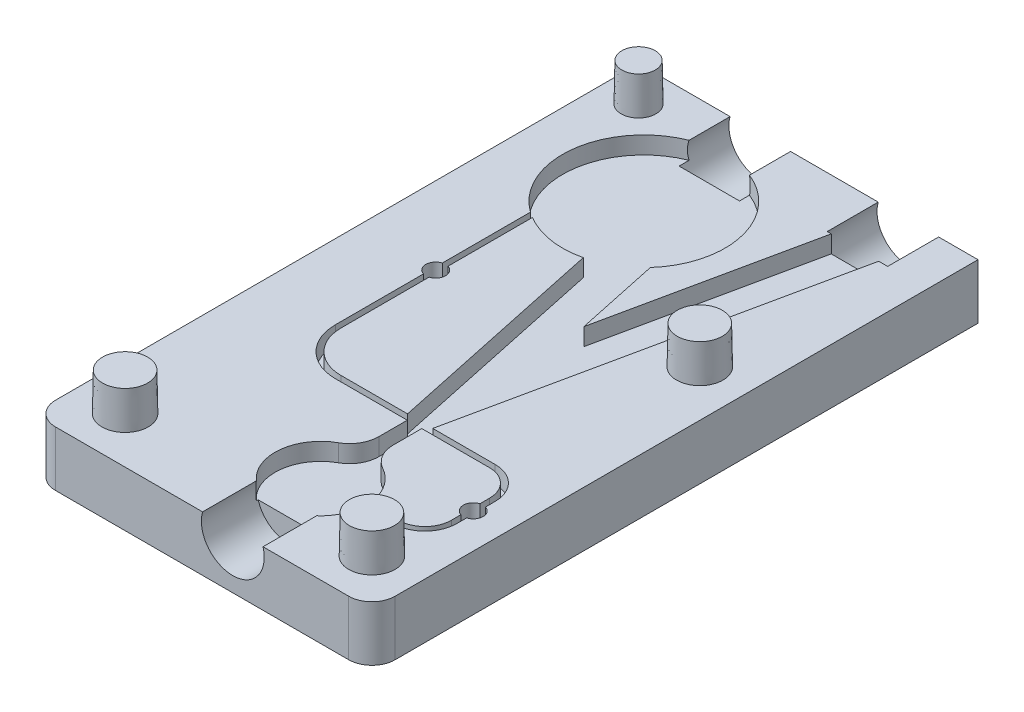
from build123d import *

# Parameters (mm, degrees)
SKETCH1_W                     = 46.5
SKETCH1_H                     = 83
BOSS_EXTRUDE1_DEPTH           = 7.540625
CUT_EXTRUDE3_START            = 7.540625
CUT_EXTRUDE3_DEPTH            = 2.38125
SKETCH10_R                    = 1.35255
CUT_EXTRUDE6_DEPTH            = 4.76885
SKETCH11_W                    = 6.985
SKETCH11_H                    = 5.382155198
CUT_EXTRUDE7_DEPTH            = 2.38125
SKETCH12_R                    = 3.175
BOSS_EXTRUDE2_DEPTH           = 5.159375
BOSS_EXTRUDE2_DRAFT           = 1
BOSS_EXTRUDE2_PROFILE_2_DEPTH = 5.159375
BOSS_EXTRUDE2_PROFILE_2_DRAFT = 1
BOSS_EXTRUDE2_PROFILE_3_DEPTH = 5.159375
BOSS_EXTRUDE2_PROFILE_3_DRAFT = 1
SKETCH12_R_2                  = 2.38125
BOSS_EXTRUDE2_PROFILE_4_DEPTH = 5.159375
BOSS_EXTRUDE2_PROFILE_4_DRAFT = 1
FILLET1_R                     = 3.175
SKETCH13_R                    = 4.3053
CUT_EXTRUDE8_DEPTH            = 6.985
SKETCH14_R                    = 4.3053
CUT_EXTRUDE9_DEPTH            = 7.62


with BuildPart() as part:
    # Sketch1 → Boss-Extrude1 (new body)
    with BuildSketch(Plane(origin=(0, 0, 0), x_dir=(1, 0, 0), z_dir=(0, 1, 0))):
        Rectangle(SKETCH1_W, SKETCH1_H)
    extrude(amount=BOSS_EXTRUDE1_DEPTH)

    # Sketch2 → Cut-Extrude3 (cut)
    with BuildSketch(Plane(origin=(0, 0, 0), x_dir=(1, 0, 0), z_dir=(0, 1, 0)).offset(CUT_EXTRUDE3_START)):
        with BuildLine():
            Line((5.926342072, -15.8450122), (16.691855897, 34.802748287))
            ThreePointArc((16.691855897, 34.802748287), (16.847821053, 35.78747353), (16.9, 36.783107142))
            Line((16.9, 36.783107142), (16.9, 41.5))
            Line((16.9, 41.5), (10.55, 41.5))
            Line((10.55, 41.5), (10.55, 36.783107142))
            ThreePointArc((10.55, 36.783107142), (10.532607018, 36.451229271), (10.480618632, 36.122987524))
            Line((10.480618632, 36.122987524), (4.2, 6.575))
            Line((4.2, 6.575), (1.742353127, 18.137319476))
            ThreePointArc((1.742353127, 18.137319476), (-7.787687338, 36.612083158), (-13.035, 16.49730565))
            Line((-13.035, 16.49730565), (-13.035, -10.23))
            ThreePointArc((-13.035, -10.23), (-11.164876798, -14.744876798), (-6.65, -16.615))
            Line((-6.65, -16.615), (3.2078125, -16.615))
            Line((3.2078125, -16.615), (3.2078125, -20.512873774))
            ThreePointArc((3.2078125, -20.512873774), (2.656919843, -22.538622657), (1.155983232, -24.006386448))
            ThreePointArc((1.155983232, -24.006386448), (-2.044457088, -29.201835269), (0.7075, -34.648140337))
            Line((0.7075, -34.648140337), (0.7075, -41.5))
            Line((0.7075, -41.5), (7.6925, -41.5))
            Line((7.6925, -41.5), (7.6925, -34.648140337))
            ThreePointArc((7.6925, -34.648140337), (9.624653372, -32.569132052), (10.438131483, -29.8499878))
            Line((10.438131483, -29.8499878), (14.4748, -29.8499878))
            ThreePointArc((14.4748, -29.8499878), (17.575454609, -28.565654609), (18.8597878, -25.465))
            Line((18.8597878, -25.465), (18.8597878, -20.23))
            ThreePointArc((18.8597878, -20.23), (17.575454609, -17.129345391), (14.4748, -15.8450122))
            Line((14.4748, -15.8450122), (5.926342072, -15.8450122))
        make_face()
        with BuildLine():
            Line((14.4748, -29.08), (10.43813073, -29.08))
            ThreePointArc((10.43813073, -29.08), (9.489135484, -26.135203334), (7.244016768, -24.006386448))
            ThreePointArc((7.244016768, -24.006386448), (5.743080157, -22.538622657), (5.1921875, -20.512873774))
            Line((5.1921875, -20.512873774), (5.1921875, -16.615))
            Line((5.1921875, -16.615), (14.4748, -16.615))
            ThreePointArc((14.4748, -16.615), (17.030991014, -17.673808986), (18.0898, -20.23))
            Line((18.0898, -20.23), (18.0898, -25.465))
            ThreePointArc((18.0898, -25.465), (17.030991014, -28.021191014), (14.4748, -29.08))
        make_face(mode=Mode.SUBTRACT)
        with BuildLine():
            Line((-4.021712531, 14.713303237), (2.473657928, -15.8450122))
            Line((2.473657928, -15.8450122), (-6.65, -15.8450122))
            ThreePointArc((-6.65, -15.8450122), (-10.620413203, -14.200413203), (-12.2650122, -10.23))
            Line((-12.2650122, -10.23), (-12.2650122, 15.993340762))
            ThreePointArc((-12.2650122, 15.993340762), (-8.267823292, 14.551807439), (-4.021712531, 14.713303237))
        make_face(mode=Mode.SUBTRACT)
    extrude(amount=-CUT_EXTRUDE3_DEPTH, mode=Mode.SUBTRACT)

    # Sketch10 → Cut-Extrude6 (cut)
    with BuildSketch(Plane(origin=(0, 7.540625, 0), x_dir=(1, 0, 0), z_dir=(0, 1, 0))):
        with Locations(Location((18.4747939, -22.8475, 0), (0, 0, 270))):
            Circle(SKETCH10_R)
        with Locations(Location((-12.6500061, 3.133652825, 0), (0, 0, 270))):
            Circle(SKETCH10_R)
    extrude(amount=-CUT_EXTRUDE6_DEPTH, mode=Mode.SUBTRACT)

    # Sketch11 → Cut-Extrude7 (cut)
    with BuildSketch(Plane(origin=(0, 7.540625, 0), x_dir=(1, 0, 0), z_dir=(0, 1, 0))):
        with Locations((-6.56, 38.808922401)):
            Rectangle(SKETCH11_W, SKETCH11_H)
    extrude(amount=-CUT_EXTRUDE7_DEPTH, mode=Mode.SUBTRACT)


with BuildPart() as boss_extrude2_tool:
    # Sketch12 → Boss-Extrude2 (with draft: the straight prism first)
    with BuildSketch(Plane(origin=(0, 7.540625, 0), x_dir=(1, 0, 0), z_dir=(0, 1, 0))):
        with Locations((-16.9, -35.15)):
            Circle(SKETCH12_R)
    extrude(amount=BOSS_EXTRUDE2_DEPTH)
    # Boss-Extrude2: the draft: its side faces are tilted about the plane it starts from
    boss_extrude2_sides = [boss_extrude2_tool.faces().sort_by_distance(p)[0] for p in [
        (-20.075, 10.1203125, 35.15),
    ]]
    draft(boss_extrude2_sides, Plane(origin=(0, 7.540625, 0), x_dir=(1, 0, 0), z_dir=(0, 1, 0)), BOSS_EXTRUDE2_DRAFT)


with BuildPart() as part_1:
    add(part.part)

    # Boss-Extrude2: add boss_extrude2_tool
    add(boss_extrude2_tool.part)


with BuildPart() as boss_extrude2_profile_2_tool:
    # Sketch12 → Boss-Extrude2 profile 2 (with draft: the straight prism first)
    with BuildSketch(Plane(origin=(0, 7.540625, 0), x_dir=(1, 0, 0), z_dir=(0, 1, 0))):
        with Locations((16.9, -35.15)):
            Circle(SKETCH12_R)
    extrude(amount=BOSS_EXTRUDE2_PROFILE_2_DEPTH)
    # Boss-Extrude2 profile 2: the draft: its side faces are tilted about the plane it starts from
    boss_extrude2_profile_2_sides = [boss_extrude2_profile_2_tool.faces().sort_by_distance(p)[0] for p in [
        (13.725, 10.1203125, 35.15),
    ]]
    draft(boss_extrude2_profile_2_sides, Plane(origin=(0, 7.540625, 0), x_dir=(1, 0, 0), z_dir=(0, 1, 0)), BOSS_EXTRUDE2_PROFILE_2_DRAFT)


with BuildPart() as part_2:
    add(part_1.part)

    # Boss-Extrude2 profile 2: add boss_extrude2_profile_2_tool
    add(boss_extrude2_profile_2_tool.part)


with BuildPart() as boss_extrude2_profile_3_tool:
    # Sketch12 → Boss-Extrude2 profile 3 (with draft: the straight prism first)
    with BuildSketch(Plane(origin=(0, 7.540625, 0), x_dir=(1, 0, 0), z_dir=(0, 1, 0))):
        with Locations((16.9, 9.75)):
            Circle(SKETCH12_R)
    extrude(amount=BOSS_EXTRUDE2_PROFILE_3_DEPTH)
    # Boss-Extrude2 profile 3: the draft: its side faces are tilted about the plane it starts from
    boss_extrude2_profile_3_sides = [boss_extrude2_profile_3_tool.faces().sort_by_distance(p)[0] for p in [
        (13.725, 10.1203125, -9.75),
    ]]
    draft(boss_extrude2_profile_3_sides, Plane(origin=(0, 7.540625, 0), x_dir=(1, 0, 0), z_dir=(0, 1, 0)), BOSS_EXTRUDE2_PROFILE_3_DRAFT)


with BuildPart() as part_3:
    add(part_2.part)

    # Boss-Extrude2 profile 3: add boss_extrude2_profile_3_tool
    add(boss_extrude2_profile_3_tool.part)


with BuildPart() as boss_extrude2_profile_4_tool:
    # Sketch12 → Boss-Extrude2 profile 4 (with draft: the straight prism first)
    with BuildSketch(Plane(origin=(0, 7.540625, 0), x_dir=(1, 0, 0), z_dir=(0, 1, 0))):
        with Locations((-18.4748, 36.7375)):
            Circle(SKETCH12_R_2)
    extrude(amount=BOSS_EXTRUDE2_PROFILE_4_DEPTH)
    # Boss-Extrude2 profile 4: the draft: its side faces are tilted about the plane it starts from
    boss_extrude2_profile_4_sides = [boss_extrude2_profile_4_tool.faces().sort_by_distance(p)[0] for p in [
        (-20.85605, 10.1203125, -36.7375),
    ]]
    draft(boss_extrude2_profile_4_sides, Plane(origin=(0, 7.540625, 0), x_dir=(1, 0, 0), z_dir=(0, 1, 0)), BOSS_EXTRUDE2_PROFILE_4_DRAFT)


with BuildPart() as part_4:
    add(part_3.part)

    # Boss-Extrude2 profile 4: add boss_extrude2_profile_4_tool
    add(boss_extrude2_profile_4_tool.part)

    # Fillet1
    fillet1_edges = [part_4.edges().sort_by_distance(p)[0] for p in [
        (23.25, 3.7703125, 41.5),
        (-23.25, 3.7703125, 41.5),
        (-23.25, 3.7703125, -41.5),
    ]]
    fillet(fillet1_edges, radius=FILLET1_R)

    # Sketch13 → Cut-Extrude8 (cut)
    with BuildSketch(Plane(origin=(0, 0, -41.5), x_dir=(-1, 0, 0), z_dir=(0, 0, -1))):
        with Locations((-13.725, 6.35)):
            Circle(SKETCH13_R)
        with Locations((6.56, 6.35)):
            Circle(SKETCH13_R)
    extrude(amount=-CUT_EXTRUDE8_DEPTH, mode=Mode.SUBTRACT)

    # Sketch14 → Cut-Extrude9 (cut)
    with BuildSketch(Plane.XY.offset(41.5)):
        with Locations((4.2, 6.35)):
            Circle(SKETCH14_R)
    extrude(amount=-CUT_EXTRUDE9_DEPTH, mode=Mode.SUBTRACT)


solid = part_4.part
